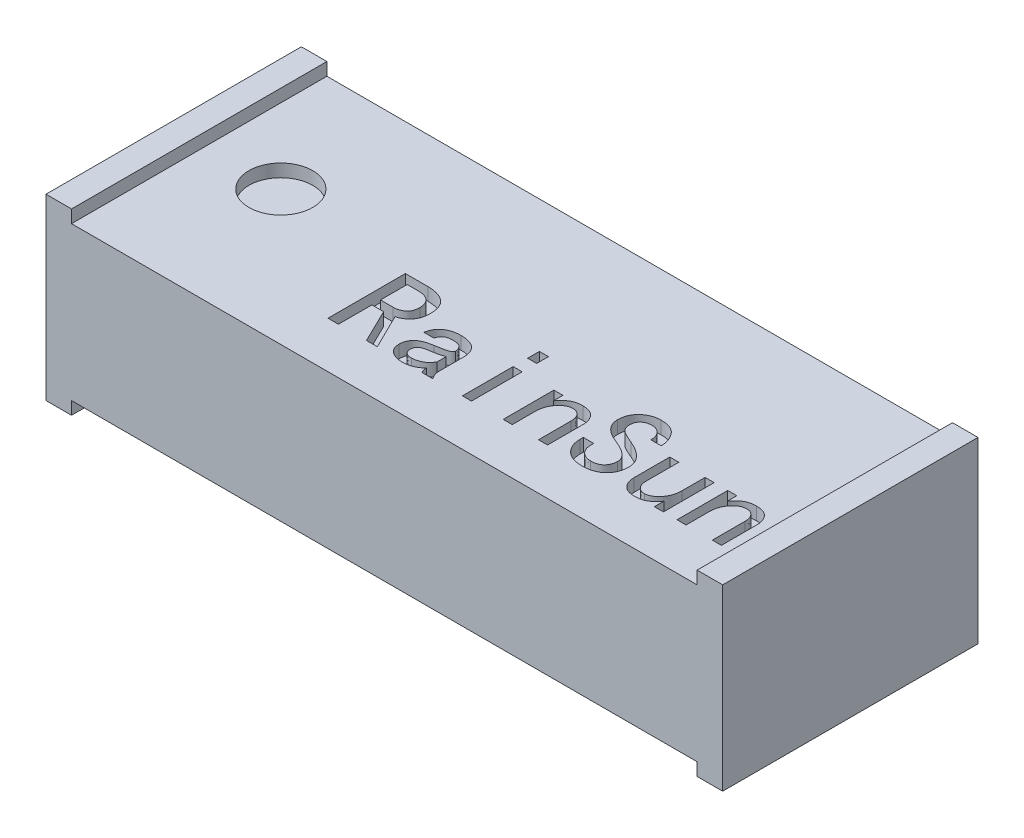
from build123d import *

# Parameters (mm, degrees)
SKETCH_1_W          = 5.1
SKETCH_1_H          = 2
EXTRUDE_1_DEPTH     = 1.2
EXTRUDE_2_DEPTH     = 2
SKETCH_3_W          = 0.070916585
SKETCH_3_H          = 0.092191561
SKETCH_3_H_2        = 0.397132879
CUT_EXTRUDE_1_DEPTH = 0.1
SKETCH_4_R          = 0.25
CUT_EXTRUDE_2_DEPTH = 0.1


with BuildPart() as part:
    # 草图1 → 凸台-拉伸1 (new body)
    with BuildSketch(Plane(origin=(0, 0, 0), x_dir=(1, 0, 0), z_dir=(0, 1, 0))):
        with Locations((2.55, 1)):
            Rectangle(SKETCH_1_W, SKETCH_1_H)
    extrude(amount=EXTRUDE_1_DEPTH)

    # 草图2 → 凸台-拉伸2 (add)
    with BuildSketch(Plane.XY):
        Polygon((0, 1.2), (0.1, 1.2), (0.1, 1.3), (-0.1, 1.3), (-0.1, -0.1), (0.1, -0.1), (0.1, 0), (0, 0), align=None)
        Polygon((5.1, 0), (5.1, 1.2), (5, 1.2), (5, 1.3), (5.2, 1.3), (5.2, -0.1), (5, -0.1), (5, 0), align=None)
    extrude(amount=-EXTRUDE_2_DEPTH)

    # 草图3 → 切除-拉伸1 (cut)
    with BuildSketch(Plane(origin=(0, 1.2, 0), x_dir=(1, 0, 0), z_dir=(0, 1, 0))):
        with BuildLine():
            Line((2.132303458, 0.362905632), (2.047203555, 0.362905632))
            Line((2.047203555, 0.362905632), (1.919553701, 0.625296999))
            Line((1.919553701, 0.625296999), (1.82736214, 0.625296999))
            Line((1.82736214, 0.625296999), (1.82736214, 0.362905632))
            Line((1.82736214, 0.362905632), (1.745808067, 0.362905632))
            Line((1.745808067, 0.362905632), (1.745808067, 0.969242438))
            Line((1.745808067, 0.969242438), (1.923099531, 0.969242438))
            add(Edge.make_bspline(
                [(1.923099531, 0.969242438), (1.930019325, 0.96910517), (1.943577381, 0.968836218), (1.963435314, 0.967060804), (1.98225278, 0.963736569), (2.000068059, 0.959253495), (2.016977041, 0.953710637), (2.032769593, 0.946496704), (2.047689113, 0.938263513), (2.061546601, 0.92868351), (2.074089342, 0.917678393), (2.085070324, 0.904995484), (2.094201081, 0.890619031), (2.101796424, 0.874669065), (2.10745827, 0.857111876), (2.111708854, 0.837998385), (2.114176522, 0.817274373), (2.114439057, 0.802901486), (2.114574311, 0.795496804)],
                knots=[0, 0, 0, 0, 2.076e-05, 4.0675e-05, 5.974e-05, 7.8023e-05, 9.5756e-05, 0.000113037, 0.000130028, 0.000146822, 0.000163476, 0.000179957, 0.000196969, 0.000214416, 0.000232813, 0.000252186, 0.000273085, 0.000295293, 0.000295293, 0.000295293, 0.000295293], degree=3))
            add(Edge.make_bspline(
                [(2.114574311, 0.795496804), (2.114490748, 0.78975741), (2.114327689, 0.778558079), (2.112561841, 0.762276115), (2.109847395, 0.746989298), (2.106049821, 0.732685691), (2.10109468, 0.719367569), (2.094840905, 0.707091601), (2.087655306, 0.695725321), (2.07663466, 0.682257534), (2.061413189, 0.667680711), (2.041540406, 0.653252365), (2.02023322, 0.642317669), (2.005092899, 0.638054855), (1.997561945, 0.635934486)],
                knots=[0, 0, 0, 0, 1.7212e-05, 3.3586e-05, 4.9067e-05, 6.3753e-05, 7.7925e-05, 9.1609e-05, 0.000105016, 0.000118183, 0.000143724, 0.000167998, 0.000191667, 0.000215092, 0.000215092, 0.000215092, 0.000215092], degree=3))
            Line((1.997561945, 0.635934486), (2.132303458, 0.362905632))
        make_face()
        with BuildLine():
            add(Edge.make_bspline(
                [(2.033020238, 0.795496804), (2.032898717, 0.799526582), (2.032661633, 0.807388598), (2.031416001, 0.818883936), (2.028996239, 0.829682299), (2.02581322, 0.839871783), (2.021311833, 0.849228135), (2.016315124, 0.858138301), (2.009965622, 0.866160259), (2.002921923, 0.873727691), (1.994716239, 0.880444321), (1.985389742, 0.886318453), (1.974848619, 0.891108049), (1.963173069, 0.89503066), (1.950398133, 0.898192211), (1.936426114, 0.900370277), (1.921286983, 0.901696583), (1.910801472, 0.901811934), (1.905370384, 0.901871682)],
                knots=[0, 0, 0, 0, 1.2093e-05, 2.3594e-05, 3.4619e-05, 4.5251e-05, 5.5533e-05, 6.5714e-05, 7.5827e-05, 8.6139e-05, 9.6682e-05, 0.00010754, 0.000119115, 0.000131325, 0.000144448, 0.000158547, 0.000173706, 0.000189996, 0.000189996, 0.000189996, 0.000189996], degree=3))
            Line((1.905370384, 0.901871682), (1.82736214, 0.901871682))
            Line((1.82736214, 0.901871682), (1.82736214, 0.692667755))
            Line((1.82736214, 0.692667755), (1.92664536, 0.692667755))
            add(Edge.make_bspline(
                [(1.92664536, 0.692667755), (1.933542656, 0.692929072), (1.947042473, 0.693440538), (1.966539441, 0.697928031), (1.984743873, 0.705098821), (1.998692122, 0.713456208), (2.008785234, 0.721748559), (2.015254248, 0.729256854), (2.020836049, 0.737704559), (2.025265902, 0.747295089), (2.028838863, 0.757850645), (2.031290446, 0.769486695), (2.032711651, 0.782153493), (2.032914862, 0.790940332), (2.033020238, 0.795496804)],
                knots=[0, 0, 0, 0, 2.0669e-05, 4.0454e-05, 5.9671e-05, 7.9176e-05, 8.8962e-05, 9.8734e-05, 0.000108788, 0.000119244, 0.000130333, 0.000142156, 0.000154846, 0.000168514, 0.000168514, 0.000168514, 0.000168514], degree=3))
        make_face(mode=Mode.SUBTRACT)
        with BuildLine():
            Line((2.568440458, 0.362905632), (2.483340556, 0.362905632))
            add(Edge.make_bspline(
                [(2.483340556, 0.362905632), (2.481128465, 0.365613243), (2.476391818, 0.371410923), (2.472141554, 0.382959901), (2.469608627, 0.396888989), (2.469315411, 0.407060366), (2.469157238, 0.412547242)],
                knots=[0, 0, 0, 0, 1.0428e-05, 2.2329e-05, 3.6366e-05, 5.2808e-05, 5.2808e-05, 5.2808e-05, 5.2808e-05], degree=3))
            add(Edge.make_bspline(
                [(2.469157238, 0.412547242), (2.464877254, 0.408024525), (2.456378746, 0.399044036), (2.441903983, 0.387375451), (2.426012682, 0.37765135), (2.408959999, 0.369644251), (2.390992154, 0.363575767), (2.372550486, 0.359047308), (2.353624361, 0.356366031), (2.3408591, 0.355999157), (2.334415726, 0.355813974)],
                knots=[0, 0, 0, 0, 1.8666e-05, 3.7063e-05, 5.5578e-05, 7.4436e-05, 9.3458e-05, 0.000112378, 0.00013134, 0.000150667, 0.000150667, 0.000150667, 0.000150667], degree=3))
            add(Edge.make_bspline(
                [(2.334415726, 0.355813974), (2.329769935, 0.355857745), (2.320629543, 0.355943862), (2.307277261, 0.357566426), (2.294408878, 0.359496069), (2.282207371, 0.362778084), (2.270402245, 0.366603233), (2.25931665, 0.371736248), (2.24853696, 0.377260025), (2.238638101, 0.384033947), (2.229409058, 0.391365659), (2.221456577, 0.399750757), (2.214752717, 0.408859151), (2.209088377, 0.418671717), (2.20496867, 0.42937771), (2.20190469, 0.440818009), (2.200065, 0.453024547), (2.199806306, 0.461438432), (2.199674214, 0.465734681)],
                knots=[0, 0, 0, 0, 1.3926e-05, 2.7399e-05, 4.031e-05, 5.2924e-05, 6.5258e-05, 7.7485e-05, 8.9529e-05, 0.000101549, 0.000113404, 0.000124829, 0.000136097, 0.000147272, 0.000158709, 0.0001704, 0.000182751, 0.000195638, 0.000195638, 0.000195638, 0.000195638], degree=3))
            add(Edge.make_bspline(
                [(2.199674214, 0.465734681), (2.199754147, 0.470075629), (2.199909838, 0.478530727), (2.201735679, 0.490872149), (2.204394268, 0.502614845), (2.208413301, 0.513610267), (2.213219429, 0.524072371), (2.219545111, 0.533644574), (2.226705092, 0.542745797), (2.235105672, 0.551086958), (2.24463829, 0.558770521), (2.255434421, 0.565663633), (2.267392833, 0.571990658), (2.280491123, 0.577854013), (2.295002864, 0.58252137), (2.310567724, 0.586947533), (2.327372012, 0.59059423), (2.339045738, 0.592436483), (2.345053214, 0.593384535)],
                knots=[0, 0, 0, 0, 1.3012e-05, 2.5344e-05, 3.7353e-05, 4.9067e-05, 6.0405e-05, 7.1807e-05, 8.3395e-05, 9.5095e-05, 0.000107237, 0.00012006, 0.000133455, 0.000147803, 0.000163044, 0.000179135, 0.000196343, 0.000214586, 0.000214586, 0.000214586, 0.000214586], degree=3))
            add(Edge.make_bspline(
                [(2.345053214, 0.593384535), (2.3530725, 0.594605005), (2.368621339, 0.596971412), (2.391121989, 0.601221653), (2.412100645, 0.60569993), (2.428425044, 0.610070926), (2.440351285, 0.613599505), (2.447881792, 0.616727507), (2.4544438, 0.619732061), (2.459618163, 0.623341674), (2.463963527, 0.626849873), (2.466812582, 0.630886611), (2.468924148, 0.635039569), (2.469080139, 0.638011455), (2.469157238, 0.639480316)],
                knots=[0, 0, 0, 0, 2.4333e-05, 4.7179e-05, 6.8689e-05, 8.8662e-05, 9.7883e-05, 0.000105955, 0.00011312, 0.000119458, 0.000124857, 0.000129742, 0.000134209, 0.000138575, 0.000138575, 0.000138575, 0.000138575], degree=3))
            add(Edge.make_bspline(
                [(2.469157238, 0.639480316), (2.468924066, 0.643041301), (2.468450444, 0.650274414), (2.465483028, 0.66115104), (2.460099718, 0.671739025), (2.454580472, 0.68064406), (2.448603361, 0.687251964), (2.442796448, 0.691682002), (2.43578008, 0.695259787), (2.427695334, 0.698345944), (2.418397169, 0.700437318), (2.408019358, 0.702220129), (2.39641384, 0.703022958), (2.388304072, 0.703208226), (2.384057336, 0.703305243)],
                knots=[0, 0, 0, 0, 1.0689e-05, 2.1712e-05, 3.3518e-05, 4.6231e-05, 5.3015e-05, 6.0134e-05, 6.8006e-05, 7.6567e-05, 8.6027e-05, 9.6542e-05, 0.000108135, 0.00012088, 0.00012088, 0.00012088, 0.00012088], degree=3))
            add(Edge.make_bspline(
                [(2.384057336, 0.703305243), (2.377437395, 0.703104286), (2.365088388, 0.702729418), (2.347856556, 0.700009613), (2.333463294, 0.694988467), (2.321830506, 0.687804247), (2.312643042, 0.678795533), (2.305318833, 0.66825311), (2.29923103, 0.65630689), (2.296711347, 0.647545556), (2.295411604, 0.643026145)],
                knots=[0, 0, 0, 0, 1.9858e-05, 3.7044e-05, 5.2124e-05, 6.5279e-05, 7.7724e-05, 9.0441e-05, 0.000103655, 0.000117734, 0.000117734, 0.000117734, 0.000117734], degree=3))
            Line((2.295411604, 0.643026145), (2.21740336, 0.643026145))
            add(Edge.make_bspline(
                [(2.21740336, 0.643026145), (2.218097796, 0.647641636), (2.219467432, 0.656744774), (2.223103398, 0.669865248), (2.227648042, 0.682377723), (2.233617133, 0.694035994), (2.240624028, 0.705051965), (2.248781372, 0.715337696), (2.258214271, 0.724824715), (2.268685176, 0.73362248), (2.280227312, 0.741473248), (2.29266318, 0.748283871), (2.305818797, 0.754303411), (2.319898683, 0.758924661), (2.334767399, 0.762678353), (2.350454835, 0.765217189), (2.366993893, 0.766853413), (2.378274856, 0.767036382), (2.384057336, 0.767130169)],
                knots=[0, 0, 0, 0, 1.399e-05, 2.7593e-05, 4.0766e-05, 5.3863e-05, 6.6796e-05, 7.9882e-05, 9.3161e-05, 0.000106865, 0.000120853, 0.00013496, 0.000149361, 0.000164187, 0.000179349, 0.000195325, 0.000211817, 0.00022916, 0.00022916, 0.00022916, 0.00022916], degree=3))
            add(Edge.make_bspline(
                [(2.384057336, 0.767130169), (2.390365618, 0.767050234), (2.402569393, 0.766895595), (2.420291813, 0.765111809), (2.436802439, 0.762418463), (2.452131466, 0.758674202), (2.466202348, 0.753630856), (2.479076343, 0.747504758), (2.490743342, 0.740222483), (2.501207028, 0.731911697), (2.510383416, 0.722576586), (2.518411981, 0.712338833), (2.525051248, 0.70112976), (2.530666747, 0.689109355), (2.534802184, 0.67615951), (2.537844393, 0.66235922), (2.539685173, 0.647671893), (2.539942331, 0.637559456), (2.540073824, 0.632388657)],
                knots=[0, 0, 0, 0, 1.8918e-05, 3.6599e-05, 5.3374e-05, 6.9077e-05, 8.3865e-05, 9.8139e-05, 0.000111767, 0.000125037, 0.000138131, 0.000150951, 0.000163969, 0.000177131, 0.00019067, 0.000204658, 0.000219481, 0.000234991, 0.000234991, 0.000234991, 0.000234991], degree=3))
            Line((2.540073824, 0.632388657), (2.540073824, 0.437368047))
            add(Edge.make_bspline(
                [(2.540073824, 0.437368047), (2.540117563, 0.433902258), (2.540203788, 0.427069975), (2.541842184, 0.417091037), (2.543758703, 0.407432071), (2.548213223, 0.395093511), (2.555900795, 0.379813915), (2.564144414, 0.36869835), (2.568440458, 0.362905632)],
                knots=[0, 0, 0, 0, 1.0382e-05, 2.0467e-05, 3.0282e-05, 3.9876e-05, 5.9727e-05, 8.1331e-05, 8.1331e-05, 8.1331e-05, 8.1331e-05], degree=3))
        make_face()
        with BuildLine():
            Line((2.469157238, 0.494101316), (2.469157238, 0.565017901))
            add(Edge.make_bspline(
                [(2.469157238, 0.565017901), (2.462207519, 0.562752615), (2.448671788, 0.558340596), (2.431257095, 0.553189339), (2.415860768, 0.549433181), (2.401096895, 0.546702322), (2.383095255, 0.543307663), (2.369925471, 0.541290939), (2.36278236, 0.540197096)],
                knots=[0, 0, 0, 0, 2.1929e-05, 4.271e-05, 5.4464e-05, 6.9453e-05, 8.7742e-05, 0.000109419, 0.000109419, 0.000109419, 0.000109419], degree=3))
            add(Edge.make_bspline(
                [(2.36278236, 0.540197096), (2.358531569, 0.539569804), (2.350399228, 0.538369707), (2.338809285, 0.536186785), (2.328430111, 0.533547406), (2.319154742, 0.530679801), (2.311011802, 0.5274976), (2.304112127, 0.523740891), (2.298265564, 0.519874076), (2.292126015, 0.514256163), (2.286423375, 0.506301091), (2.281196121, 0.496018283), (2.278333491, 0.484664773), (2.277902317, 0.476824273), (2.277682458, 0.47282634)],
                knots=[0, 0, 0, 0, 1.289e-05, 2.4661e-05, 3.5363e-05, 4.4999e-05, 5.3778e-05, 6.1534e-05, 6.8528e-05, 7.4756e-05, 8.6392e-05, 9.7668e-05, 0.000109199, 0.000121196, 0.000121196, 0.000121196, 0.000121196], degree=3))
            add(Edge.make_bspline(
                [(2.277682458, 0.47282634), (2.277905845, 0.46939484), (2.278349177, 0.462584713), (2.28126302, 0.452666868), (2.286516046, 0.443592489), (2.293375639, 0.43509107), (2.302572836, 0.428090699), (2.313813387, 0.422996512), (2.327061721, 0.420228893), (2.336504424, 0.419843232), (2.341507385, 0.419638901)],
                knots=[0, 0, 0, 0, 1.0297e-05, 2.0436e-05, 3.0666e-05, 4.1579e-05, 5.3005e-05, 6.4993e-05, 7.8312e-05, 9.332e-05, 9.332e-05, 9.332e-05, 9.332e-05], degree=3))
            add(Edge.make_bspline(
                [(2.341507385, 0.419638901), (2.346953201, 0.419831275), (2.35816636, 0.420227382), (2.375186638, 0.423950154), (2.392863209, 0.429498077), (2.410923574, 0.437071603), (2.428490597, 0.447149929), (2.444395984, 0.460113431), (2.458170367, 0.475896343), (2.465437716, 0.487938159), (2.469157238, 0.494101316)],
                knots=[0, 0, 0, 0, 1.6318e-05, 3.36e-05, 5.2042e-05, 7.1873e-05, 9.2235e-05, 0.000112582, 0.000133152, 0.000154717, 0.000154717, 0.000154717, 0.000154717], degree=3))
        make_face(mode=Mode.SUBTRACT)
        with Locations((2.834377654, 0.919600829)):
            Rectangle(SKETCH_3_W, SKETCH_3_H)
        with Locations((2.834377654, 0.561472072)):
            Rectangle(SKETCH_3_W, SKETCH_3_H_2)
        with BuildLine():
            Line((3.465535264, 0.362905632), (3.394618679, 0.362905632))
            Line((3.394618679, 0.362905632), (3.394618679, 0.61820534))
            add(Edge.make_bspline(
                [(3.394618679, 0.61820534), (3.394395067, 0.624967918), (3.393969659, 0.637833363), (3.389997518, 0.656081244), (3.383287733, 0.672120052), (3.373891059, 0.685800169), (3.362293827, 0.696856364), (3.348644452, 0.704841036), (3.333152567, 0.709544011), (3.322246545, 0.710106311), (3.316610435, 0.710396901)],
                knots=[0, 0, 0, 0, 2.0267e-05, 3.8557e-05, 5.568e-05, 7.2109e-05, 8.7995e-05, 0.000103357, 0.000119143, 0.000136027, 0.000136027, 0.000136027, 0.000136027], degree=3))
            add(Edge.make_bspline(
                [(3.316610435, 0.710396901), (3.312790822, 0.710236712), (3.30513156, 0.709915492), (3.2937555, 0.707561291), (3.282519078, 0.703914196), (3.271513019, 0.698554262), (3.260785253, 0.6916323), (3.250042897, 0.68345264), (3.239537275, 0.673688041), (3.229458881, 0.662475691), (3.2199207, 0.650326192), (3.211579601, 0.637233857), (3.204618275, 0.623407068), (3.198943834, 0.60883982), (3.194517244, 0.593582649), (3.191149811, 0.577619576), (3.189371722, 0.560899878), (3.18909914, 0.54952502), (3.188960581, 0.543742925)],
                knots=[0, 0, 0, 0, 1.1453e-05, 2.2965e-05, 3.4718e-05, 4.6818e-05, 5.957e-05, 7.2966e-05, 8.7277e-05, 0.000102525, 0.000118155, 0.000133566, 0.000149012, 0.000164522, 0.000180397, 0.000196623, 0.000213403, 0.000230751, 0.000230751, 0.000230751, 0.000230751], degree=3))
            Line((3.188960581, 0.543742925), (3.188960581, 0.362905632))
            Line((3.188960581, 0.362905632), (3.118043995, 0.362905632))
            Line((3.118043995, 0.362905632), (3.118043995, 0.760038511))
            Line((3.118043995, 0.760038511), (3.188960581, 0.760038511))
            Line((3.188960581, 0.760038511), (3.188960581, 0.685576096))
            add(Edge.make_bspline(
                [(3.188960581, 0.685576096), (3.193717737, 0.691788506), (3.202958383, 0.703855944), (3.218190835, 0.720149459), (3.234040887, 0.734205341), (3.250737194, 0.7463273), (3.269209909, 0.755869701), (3.290002208, 0.76253894), (3.313179737, 0.766451197), (3.329420883, 0.766897544), (3.33788541, 0.767130169)],
                knots=[0, 0, 0, 0, 2.3463e-05, 4.5577e-05, 6.679e-05, 8.6941e-05, 0.000107322, 0.000128876, 0.000152194, 0.000177574, 0.000177574, 0.000177574, 0.000177574], degree=3))
            add(Edge.make_bspline(
                [(3.33788541, 0.767130169), (3.343056341, 0.767048552), (3.353078391, 0.766890364), (3.367572778, 0.765127238), (3.381068398, 0.762392561), (3.39363315, 0.75860306), (3.40523314, 0.753674204), (3.415708224, 0.747382317), (3.425234116, 0.740125659), (3.433801398, 0.731847143), (3.441178511, 0.722656351), (3.447717235, 0.712966116), (3.453285111, 0.702699444), (3.457662759, 0.691777369), (3.461311766, 0.68039071), (3.463759756, 0.668415464), (3.465213185, 0.655888479), (3.465426645, 0.647363879), (3.465535264, 0.643026145)],
                knots=[0, 0, 0, 0, 1.5505e-05, 3.0052e-05, 4.3728e-05, 5.6773e-05, 6.9361e-05, 8.1433e-05, 9.3332e-05, 0.00010522, 0.000117075, 0.000128621, 0.000140255, 0.000152034, 0.000163872, 0.00017608, 0.00018864, 0.000201652, 0.000201652, 0.000201652, 0.000201652], degree=3))
            Line((3.465535264, 0.643026145), (3.465535264, 0.362905632))
        make_face()
        with BuildLine():
            add(Edge.make_bspline(
                [(3.933584728, 0.533105437), (3.933438904, 0.526488336), (3.933154002, 0.51356024), (3.930764579, 0.494641931), (3.926722588, 0.476780312), (3.921051269, 0.459963586), (3.913801335, 0.444235933), (3.904920221, 0.429514047), (3.894410461, 0.415838331), (3.882292056, 0.403380078), (3.868876814, 0.392182973), (3.854205277, 0.382431095), (3.838386128, 0.37409527), (3.821313371, 0.367434006), (3.803168347, 0.362155128), (3.783813669, 0.358533451), (3.763351239, 0.356269645), (3.749295256, 0.355968114), (3.742109947, 0.355813974)],
                knots=[0, 0, 0, 0, 1.9846e-05, 3.8774e-05, 5.7093e-05, 7.4701e-05, 9.1918e-05, 0.000108945, 0.000126176, 0.000143543, 0.00016098, 0.0001785, 0.000196299, 0.000214516, 0.000233385, 0.000252908, 0.000273517, 0.000295069, 0.000295069, 0.000295069, 0.000295069], degree=3))
            add(Edge.make_bspline(
                [(3.742109947, 0.355813974), (3.734923094, 0.355953426), (3.720902711, 0.356225475), (3.700534169, 0.358679503), (3.681283825, 0.362383446), (3.663326014, 0.367949923), (3.646490241, 0.374845901), (3.631043733, 0.383549453), (3.616552863, 0.393444828), (3.603712806, 0.405254861), (3.591930896, 0.417865729), (3.582014162, 0.431661777), (3.573334568, 0.446003021), (3.566409236, 0.461237778), (3.56077687, 0.477156644), (3.557088846, 0.49396986), (3.554598822, 0.511493389), (3.554321932, 0.523465748), (3.554180996, 0.529559608)],
                knots=[0, 0, 0, 0, 2.1552e-05, 4.2045e-05, 6.1464e-05, 8.0282e-05, 9.8355e-05, 0.000115932, 0.000133383, 0.000150866, 0.000168154, 0.00018507, 0.000201737, 0.000218366, 0.000235187, 0.000252295, 0.00026992, 0.000288192, 0.000288192, 0.000288192, 0.000288192], degree=3))
            Line((3.554180996, 0.529559608), (3.554180996, 0.554380413))
            Line((3.554180996, 0.554380413), (3.635735069, 0.554380413))
            Line((3.635735069, 0.554380413), (3.635735069, 0.533105437))
            add(Edge.make_bspline(
                [(3.635735069, 0.533105437), (3.635844827, 0.528811891), (3.636059383, 0.520418869), (3.637465692, 0.508229456), (3.639977441, 0.496789065), (3.643499643, 0.486180086), (3.648008109, 0.476296629), (3.653545943, 0.46723854), (3.660007787, 0.458853639), (3.669945772, 0.449032134), (3.683819336, 0.438877861), (3.70193687, 0.429635316), (3.7216279, 0.424264438), (3.735205534, 0.423548695), (3.742109947, 0.42318473)],
                knots=[0, 0, 0, 0, 1.2881e-05, 2.5179e-05, 3.6746e-05, 4.7959e-05, 5.8654e-05, 6.9262e-05, 7.9743e-05, 9.033e-05, 0.00011108, 0.000131048, 0.000151055, 0.000171756, 0.000171756, 0.000171756, 0.000171756], degree=3))
            add(Edge.make_bspline(
                [(3.742109947, 0.42318473), (3.746664728, 0.423306858), (3.755530614, 0.423544579), (3.768378356, 0.424764952), (3.780282651, 0.427164977), (3.791213274, 0.430398647), (3.801239335, 0.434636267), (3.810247509, 0.439886336), (3.818454456, 0.445966626), (3.827752383, 0.455470885), (3.837551109, 0.468705849), (3.845890862, 0.48648501), (3.851100534, 0.505759684), (3.851715507, 0.519151191), (3.852030655, 0.526013779)],
                knots=[0, 0, 0, 0, 1.3668e-05, 2.6605e-05, 3.8658e-05, 5.0042e-05, 6.0751e-05, 7.1225e-05, 8.1258e-05, 9.1288e-05, 0.000111014, 0.000130341, 0.000149899, 0.000170457, 0.000170457, 0.000170457, 0.000170457], degree=3))
            add(Edge.make_bspline(
                [(3.852030655, 0.526013779), (3.851921977, 0.528952719), (3.851706555, 0.534778268), (3.850199983, 0.543462876), (3.847733269, 0.55198365), (3.844130286, 0.560278503), (3.839583031, 0.568405319), (3.834087513, 0.576362804), (3.827577033, 0.584178945), (3.817300925, 0.594565186), (3.80194052, 0.607079868), (3.780577527, 0.621249842), (3.755601753, 0.634632649), (3.737446694, 0.642464923), (3.72792663, 0.646571974)],
                knots=[0, 0, 0, 0, 8.815e-06, 1.7472e-05, 2.6366e-05, 3.5367e-05, 4.4538e-05, 5.4265e-05, 6.4337e-05, 7.5016e-05, 9.8052e-05, 0.000123622, 0.000151826, 0.000182922, 0.000182922, 0.000182922, 0.000182922], degree=3))
            add(Edge.make_bspline(
                [(3.72792663, 0.646571974), (3.721079898, 0.649242459), (3.70778508, 0.654427941), (3.688708013, 0.662701293), (3.671096855, 0.671170776), (3.655061388, 0.680024966), (3.640422077, 0.688875585), (3.627348011, 0.698099142), (3.615795418, 0.707566988), (3.605506794, 0.717137699), (3.596829837, 0.727293143), (3.589067464, 0.737615414), (3.582821146, 0.748633726), (3.577500526, 0.759929753), (3.573378011, 0.771721108), (3.570574019, 0.783971784), (3.568577052, 0.796657578), (3.568435957, 0.80529451), (3.568364313, 0.809680121)],
                knots=[0, 0, 0, 0, 2.2046e-05, 4.2808e-05, 6.2367e-05, 8.0646e-05, 9.7741e-05, 0.000113664, 0.000128596, 0.00014253, 0.00015575, 0.00016862, 0.000181212, 0.000193668, 0.000206045, 0.000218595, 0.000231336, 0.000244479, 0.000244479, 0.000244479, 0.000244479], degree=3))
            add(Edge.make_bspline(
                [(3.568364313, 0.809680121), (3.568513495, 0.815728345), (3.568806559, 0.827609856), (3.571175909, 0.845007862), (3.575267665, 0.861504269), (3.580919338, 0.877104114), (3.588220064, 0.891796926), (3.597044212, 0.905639382), (3.607489744, 0.918625414), (3.619542915, 0.930427795), (3.632641493, 0.941129271), (3.646399656, 0.950675116), (3.660925961, 0.958547236), (3.676016638, 0.965005172), (3.69163011, 0.970209255), (3.707936985, 0.973653282), (3.724791151, 0.976048345), (3.73627904, 0.97623789), (3.742109947, 0.976334097)],
                knots=[0, 0, 0, 0, 1.814e-05, 3.5636e-05, 5.2549e-05, 6.9042e-05, 8.5311e-05, 0.000101669, 0.0001182, 0.000135194, 0.000152177, 0.000168897, 0.000185352, 0.000201648, 0.000218094, 0.000234631, 0.000251589, 0.000269068, 0.000269068, 0.000269068, 0.000269068], degree=3))
            add(Edge.make_bspline(
                [(3.742109947, 0.976334097), (3.749513723, 0.976140376), (3.763883268, 0.975764395), (3.784626147, 0.973372363), (3.803755122, 0.968978276), (3.821298822, 0.963027305), (3.837241223, 0.955163315), (3.851665591, 0.945778697), (3.864299784, 0.934384572), (3.875251832, 0.92150548), (3.884635811, 0.90764312), (3.893013963, 0.893495924), (3.900158825, 0.879096455), (3.905778559, 0.864281971), (3.910256632, 0.849271348), (3.913633401, 0.833971404), (3.915429159, 0.818347322), (3.915713329, 0.807845551), (3.915855582, 0.802588462)],
                knots=[0, 0, 0, 0, 2.2213e-05, 4.3112e-05, 6.2514e-05, 8.0995e-05, 9.8556e-05, 0.000115712, 0.000132453, 0.000149404, 0.000166306, 0.000182613, 0.000198706, 0.000214461, 0.000230084, 0.000245668, 0.000261404, 0.000277177, 0.000277177, 0.000277177, 0.000277177], degree=3))
            Line((3.915855582, 0.802588462), (3.834301508, 0.802588462))
            add(Edge.make_bspline(
                [(3.834301508, 0.802588462), (3.834557613, 0.808948736), (3.835063813, 0.821520059), (3.831334734, 0.840082402), (3.824029771, 0.857637607), (3.815245507, 0.871175333), (3.806682764, 0.881075984), (3.799362354, 0.887555807), (3.791491157, 0.893092535), (3.782899171, 0.897660675), (3.773625162, 0.901151246), (3.763671416, 0.903668359), (3.753095527, 0.905099176), (3.745835159, 0.905309564), (3.742109947, 0.905417511)],
                knots=[0, 0, 0, 0, 1.9042e-05, 3.7638e-05, 5.6246e-05, 7.5807e-05, 8.5765e-05, 9.5439e-05, 0.000105057, 0.000114574, 0.00012455, 0.000134711, 0.000145316, 0.000156491, 0.000156491, 0.000156491, 0.000156491], degree=3))
            add(Edge.make_bspline(
                [(3.742109947, 0.905417511), (3.735341276, 0.905174646), (3.722437255, 0.904711641), (3.704175952, 0.900271614), (3.688072618, 0.893042403), (3.674433228, 0.882795051), (3.663341077, 0.870245999), (3.655416908, 0.855372104), (3.650759357, 0.838454326), (3.650205985, 0.826520079), (3.649918386, 0.820317609)],
                knots=[0, 0, 0, 0, 2.0276e-05, 3.8655e-05, 5.599e-05, 7.2879e-05, 8.9446e-05, 0.000105839, 0.000123012, 0.000141596, 0.000141596, 0.000141596, 0.000141596], degree=3))
            add(Edge.make_bspline(
                [(3.649918386, 0.820317609), (3.650120772, 0.815171606), (3.650517254, 0.805090394), (3.654376033, 0.790556225), (3.660458815, 0.77709973), (3.667689902, 0.766682141), (3.675534422, 0.758905784), (3.683397709, 0.752742066), (3.693180918, 0.746349007), (3.704905556, 0.739670943), (3.718603175, 0.73280837), (3.734074755, 0.72537402), (3.751627111, 0.717974409), (3.763990348, 0.713004374), (3.770476581, 0.710396901)],
                knots=[0, 0, 0, 0, 1.5411e-05, 3.019e-05, 4.4765e-05, 5.9558e-05, 6.7916e-05, 7.7822e-05, 8.9478e-05, 0.000102949, 0.000118278, 0.000135431, 0.000154434, 0.000175407, 0.000175407, 0.000175407, 0.000175407], degree=3))
            add(Edge.make_bspline(
                [(3.770476581, 0.710396901), (3.776801622, 0.707731633), (3.789207817, 0.702503865), (3.80711764, 0.6939741), (3.823854567, 0.684906111), (3.839556734, 0.675620642), (3.85404931, 0.665858091), (3.867475472, 0.65574454), (3.879845129, 0.645269472), (3.891052744, 0.63435558), (3.901016582, 0.623076959), (3.909854674, 0.611507788), (3.917020174, 0.599305602), (3.923153926, 0.586890738), (3.927743339, 0.573954294), (3.931202612, 0.560746748), (3.933215052, 0.547044079), (3.93346033, 0.537795881), (3.933584728, 0.533105437)],
                knots=[0, 0, 0, 0, 2.0589e-05, 4.0385e-05, 5.9482e-05, 7.768e-05, 9.509e-05, 0.000111874, 0.000128084, 0.000143686, 0.000158759, 0.000173205, 0.000187281, 0.000201143, 0.000214685, 0.000228382, 0.000242051, 0.000256119, 0.000256119, 0.000256119, 0.000256119], degree=3))
        make_face()
        with BuildLine():
            Line((4.373267558, 0.362905632), (4.302350972, 0.362905632))
            Line((4.302350972, 0.362905632), (4.302350972, 0.437368047))
            add(Edge.make_bspline(
                [(4.302350972, 0.437368047), (4.297594337, 0.431154808), (4.2883547, 0.419085757), (4.2731151, 0.402803647), (4.257263687, 0.388683545), (4.240476651, 0.376711055), (4.222107911, 0.366988294), (4.201261433, 0.36062945), (4.178153411, 0.356429481), (4.161895491, 0.356024791), (4.153426143, 0.355813974)],
                knots=[0, 0, 0, 0, 2.3463e-05, 4.5577e-05, 6.679e-05, 8.7048e-05, 0.000107313, 0.000128826, 0.000152167, 0.000177547, 0.000177547, 0.000177547, 0.000177547], degree=3))
            add(Edge.make_bspline(
                [(4.153426143, 0.355813974), (4.148254683, 0.355894013), (4.138231608, 0.356049142), (4.1237444, 0.357833699), (4.110211048, 0.360496327), (4.09773787, 0.364546527), (4.086043538, 0.369228778), (4.07560855, 0.375574804), (4.066076048, 0.382815031), (4.057510526, 0.391097923), (4.050132945, 0.400287552), (4.043594344, 0.409978091), (4.038026435, 0.420244682), (4.033648796, 0.431166779), (4.029999786, 0.442553432), (4.027551797, 0.45452868), (4.026098368, 0.467055664), (4.025884908, 0.475580265), (4.025776289, 0.479917998)],
                knots=[0, 0, 0, 0, 1.5505e-05, 3.0052e-05, 4.3728e-05, 5.6812e-05, 6.9348e-05, 8.142e-05, 9.3319e-05, 0.000105207, 0.000117062, 0.000128608, 0.000140243, 0.000152022, 0.000163859, 0.000176068, 0.000188627, 0.000201639, 0.000201639, 0.000201639, 0.000201639], degree=3))
            Line((4.025776289, 0.479917998), (4.025776289, 0.760038511))
            Line((4.025776289, 0.760038511), (4.096692874, 0.760038511))
            Line((4.096692874, 0.760038511), (4.096692874, 0.504738803))
            add(Edge.make_bspline(
                [(4.096692874, 0.504738803), (4.096895833, 0.497970734), (4.097282239, 0.485085244), (4.101522527, 0.466915943), (4.107983461, 0.450790903), (4.117433213, 0.437148827), (4.129014495, 0.426086546), (4.142667975, 0.41810344), (4.158158747, 0.413400041), (4.169064926, 0.412837802), (4.174701118, 0.412547242)],
                knots=[0, 0, 0, 0, 2.0267e-05, 3.8586e-05, 5.5658e-05, 7.2087e-05, 8.7973e-05, 0.000103335, 0.000119121, 0.000136005, 0.000136005, 0.000136005, 0.000136005], degree=3))
            add(Edge.make_bspline(
                [(4.174701118, 0.412547242), (4.178520276, 0.412708873), (4.186178627, 0.413032982), (4.197520725, 0.415356897), (4.208730159, 0.419081945), (4.219724563, 0.424380588), (4.230596347, 0.43111089), (4.241097538, 0.439558479), (4.251613009, 0.449234053), (4.261759561, 0.460346431), (4.271265391, 0.472485592), (4.279570393, 0.485615643), (4.28675706, 0.499398836), (4.292328362, 0.514077163), (4.296802029, 0.529358167), (4.300159587, 0.545325496), (4.301940398, 0.562044021), (4.302212604, 0.573419041), (4.302350972, 0.579201218)],
                knots=[0, 0, 0, 0, 1.1453e-05, 2.2965e-05, 3.4593e-05, 4.6812e-05, 5.9494e-05, 7.2866e-05, 8.7178e-05, 0.000102328, 0.000117959, 0.000133369, 0.000148875, 0.000164508, 0.000180383, 0.000196609, 0.000213389, 0.000230736, 0.000230736, 0.000230736, 0.000230736], degree=3))
            Line((4.302350972, 0.579201218), (4.302350972, 0.760038511))
            Line((4.302350972, 0.760038511), (4.373267558, 0.760038511))
            Line((4.373267558, 0.760038511), (4.373267558, 0.362905632))
        make_face()
        with BuildLine():
            Line((4.827133704, 0.362905632), (4.756217119, 0.362905632))
            Line((4.756217119, 0.362905632), (4.756217119, 0.61820534))
            add(Edge.make_bspline(
                [(4.756217119, 0.61820534), (4.755993508, 0.624967918), (4.755568099, 0.637833363), (4.751595958, 0.656081244), (4.744886174, 0.672120052), (4.735489499, 0.685800169), (4.723892267, 0.696856364), (4.710242892, 0.704841036), (4.694751007, 0.709544011), (4.683844986, 0.710106311), (4.678208875, 0.710396901)],
                knots=[0, 0, 0, 0, 2.0267e-05, 3.8557e-05, 5.568e-05, 7.2109e-05, 8.7995e-05, 0.000103357, 0.000119143, 0.000136027, 0.000136027, 0.000136027, 0.000136027], degree=3))
            add(Edge.make_bspline(
                [(4.678208875, 0.710396901), (4.674389263, 0.710236712), (4.66673, 0.709915492), (4.65535394, 0.707561291), (4.644117518, 0.703914196), (4.63311146, 0.698554262), (4.622383694, 0.6916323), (4.611641338, 0.68345264), (4.601135716, 0.673688041), (4.591057321, 0.662475691), (4.58151914, 0.650326192), (4.573178042, 0.637233857), (4.566216716, 0.623407068), (4.560542274, 0.60883982), (4.556115684, 0.593582649), (4.552748252, 0.577619576), (4.550970163, 0.560899878), (4.550697581, 0.54952502), (4.550559021, 0.543742925)],
                knots=[0, 0, 0, 0, 1.1453e-05, 2.2965e-05, 3.4718e-05, 4.6818e-05, 5.957e-05, 7.2966e-05, 8.7277e-05, 0.000102525, 0.000118155, 0.000133566, 0.000149012, 0.000164522, 0.000180397, 0.000196623, 0.000213403, 0.000230751, 0.000230751, 0.000230751, 0.000230751], degree=3))
            Line((4.550559021, 0.543742925), (4.550559021, 0.362905632))
            Line((4.550559021, 0.362905632), (4.479642436, 0.362905632))
            Line((4.479642436, 0.362905632), (4.479642436, 0.760038511))
            Line((4.479642436, 0.760038511), (4.550559021, 0.760038511))
            Line((4.550559021, 0.760038511), (4.550559021, 0.685576096))
            add(Edge.make_bspline(
                [(4.550559021, 0.685576096), (4.555316177, 0.691788506), (4.564556824, 0.703855944), (4.579789275, 0.720149459), (4.595639328, 0.734205341), (4.612335635, 0.7463273), (4.63080835, 0.755869701), (4.651600648, 0.76253894), (4.674778178, 0.766451197), (4.691019323, 0.766897544), (4.699483851, 0.767130169)],
                knots=[0, 0, 0, 0, 2.3463e-05, 4.5577e-05, 6.679e-05, 8.6941e-05, 0.000107322, 0.000128876, 0.000152194, 0.000177574, 0.000177574, 0.000177574, 0.000177574], degree=3))
            add(Edge.make_bspline(
                [(4.699483851, 0.767130169), (4.704654782, 0.767048552), (4.714676832, 0.766890364), (4.729171219, 0.765127238), (4.742666838, 0.762392561), (4.75523159, 0.75860306), (4.766831581, 0.753674204), (4.777306665, 0.747382317), (4.786832557, 0.740125659), (4.795399839, 0.731847143), (4.802776952, 0.722656351), (4.809315676, 0.712966116), (4.814883551, 0.702699444), (4.8192612, 0.691777369), (4.822910207, 0.68039071), (4.825358196, 0.668415464), (4.826811625, 0.655888479), (4.827025085, 0.647363879), (4.827133704, 0.643026145)],
                knots=[0, 0, 0, 0, 1.5505e-05, 3.0052e-05, 4.3728e-05, 5.6773e-05, 6.9361e-05, 8.1433e-05, 9.3332e-05, 0.00010522, 0.000117075, 0.000128621, 0.000140255, 0.000152034, 0.000163872, 0.00017608, 0.00018864, 0.000201652, 0.000201652, 0.000201652, 0.000201652], degree=3))
            Line((4.827133704, 0.643026145), (4.827133704, 0.362905632))
        make_face()
    extrude(amount=-CUT_EXTRUDE_1_DEPTH, mode=Mode.SUBTRACT)

    # 草图4 → 切除-拉伸2 (cut)
    with BuildSketch(Plane(origin=(0, 1.2, 0), x_dir=(1, 0, 0), z_dir=(0, 1, 0))):
        with Locations((0.684804222, 1.054537888)):
            Circle(SKETCH_4_R)
    extrude(amount=-CUT_EXTRUDE_2_DEPTH, mode=Mode.SUBTRACT)


solid = part.part
